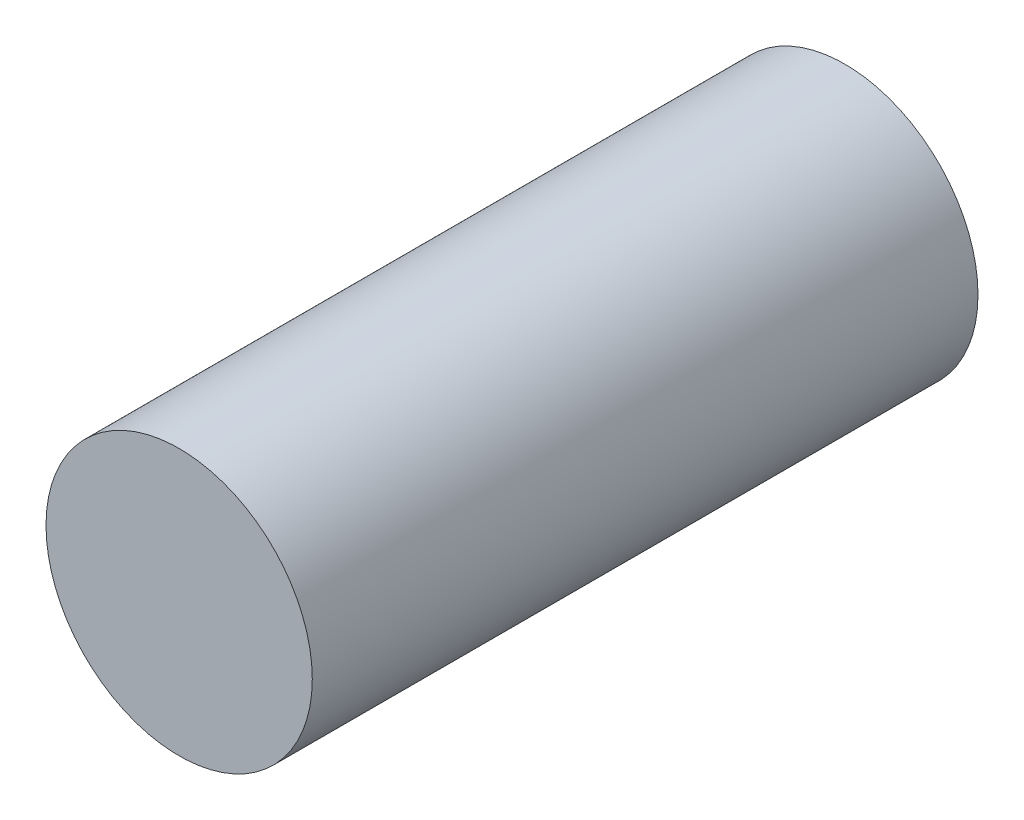
from build123d import *

# Parameters (mm, degrees)
SKETCH1_R           = 25.4
BOSS_EXTRUDE1_DEPTH = 127


with BuildPart() as part:
    # Sketch1 → Boss-Extrude1 (new body)
    with BuildSketch(Plane.XY):
        Circle(SKETCH1_R)
    extrude(amount=-BOSS_EXTRUDE1_DEPTH)


solid = part.part
